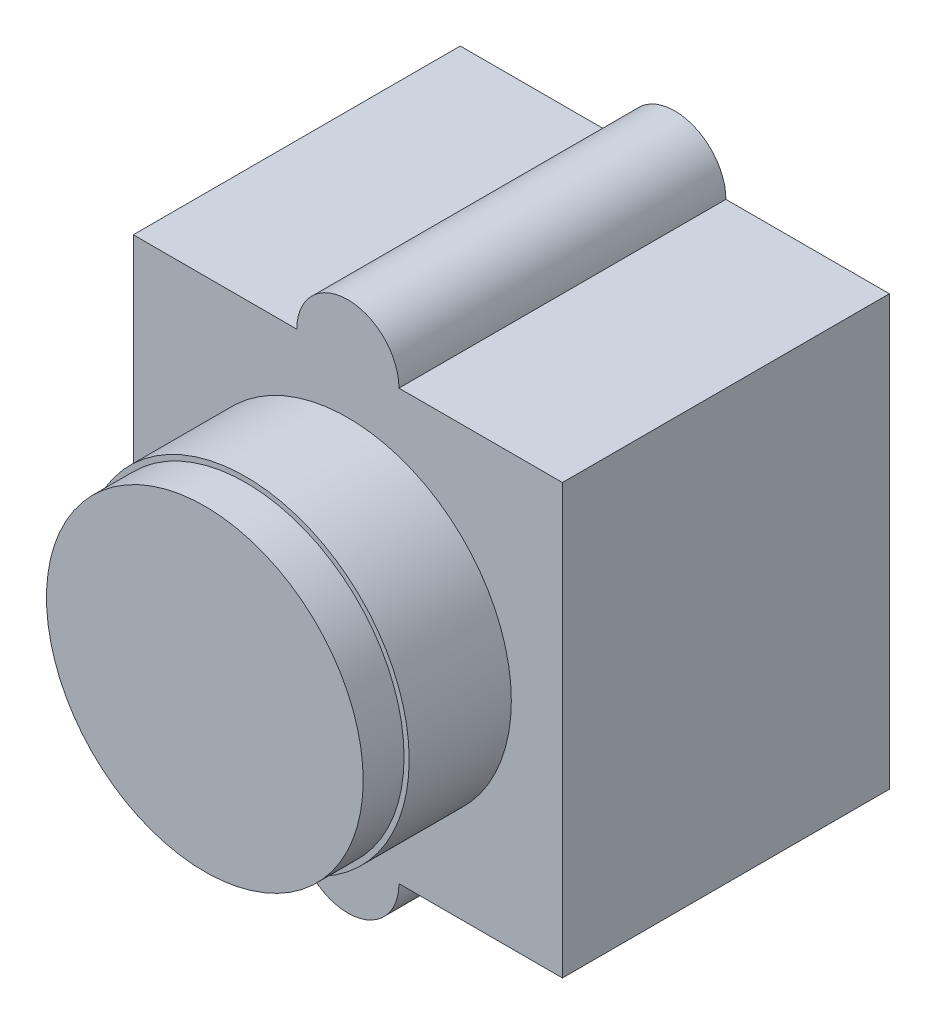
from build123d import *

# Parameters (mm, degrees)
EXTRUDE1_DEPTH = 16
SKETCH2_R      = 8
EXTRUDE2_DEPTH = 5
SKETCH3_R      = 7.75
EXTRUDE3_DEPTH = 2


with BuildPart() as part:
    # Sketch1 → Extrude1 (new body)
    with BuildSketch(Plane.XY):
        with BuildLine():
            Line((-10.5, 10.5), (-2.5, 10.5))
            ThreePointArc((-2.5, 10.5), (0, 13), (2.5, 10.5))
            Line((2.5, 10.5), (10.5, 10.5))
            Line((10.5, 10.5), (10.5, -10.5))
            Line((10.5, -10.5), (2.5, -10.5))
            ThreePointArc((2.5, -10.5), (0, -13), (-2.5, -10.5))
            Line((-2.5, -10.5), (-10.5, -10.5))
            Line((-10.5, -10.5), (-10.5, 10.5))
        make_face()
    extrude(amount=EXTRUDE1_DEPTH)

    # Sketch2 → Extrude2 (add)
    with BuildSketch(Plane.XY.offset(16)):
        Circle(SKETCH2_R)
    extrude(amount=EXTRUDE2_DEPTH)

    # Sketch3 → Extrude3 (add)
    with BuildSketch(Plane.XY.offset(21)):
        Circle(SKETCH3_R)
    extrude(amount=EXTRUDE3_DEPTH)


solid = part.part
